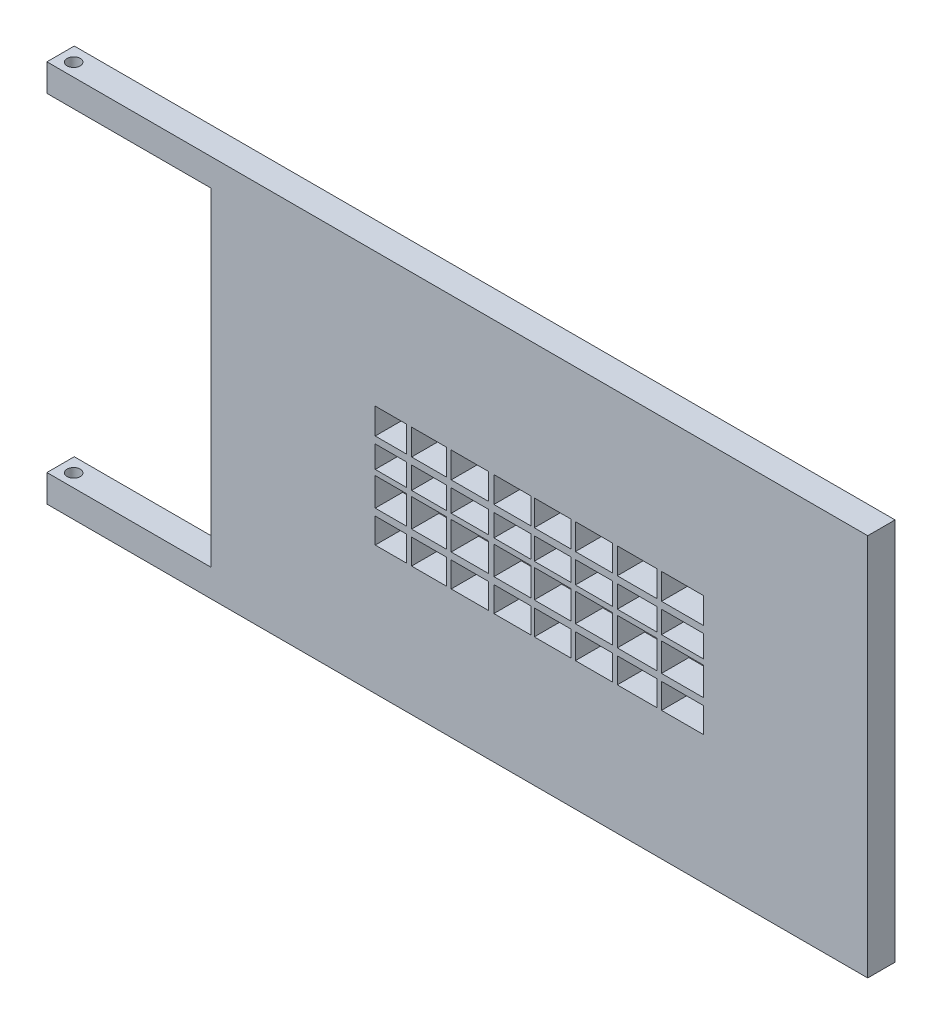
from build123d import *

# Parameters (mm, degrees)
SKETCH1_W               = 600
SKETCH1_H               = 350
BOSS_EXTRUDE1_DEPTH     = 25
SKETCH3_W               = 25
SKETCH3_H               = 25
BOSS_EXTRUDE2_DEPTH     = 150
SKETCH4_R               = 6
CUT_EXTRUDE1_DEPTH      = 370
SKETCH5_W               = 28.359872958
SKETCH5_H               = 23.680958907
SKETCH5_W_2             = 32.02157976
SKETCH5_W_3             = 34.109943658
SKETCH5_W_4             = 34.109943657
SKETCH5_W_5             = 33.413822358
SKETCH5_W_6             = 36.198307555
SKETCH5_W_7             = 38.439491831
SKETCH5_H_2             = 20.187517675
SKETCH5_H_3             = 25.762905436
SKETCH5_H_4             = 22.972002872
CUT_EXTRUDE3_DEPTH      = 30
SKETCH7_W               = 11
SKETCH7_H               = 213.013117536
BOSS_EXTRUDE4_DEPTH     = 30
SKETCH8_W               = 41.071156649
SKETCH8_H               = 6.265091692
BOSS_EXTRUDE5_DEPTH     = 30
SKETCH11_R              = 8
CUT_EXTRUDE6_DEPTH      = 217
CUT_EXTRUDE6_DEPTH_BACK = 4


with BuildPart() as part:
    # Sketch1 → Boss-Extrude1 (new body)
    with BuildSketch(Plane.XY):
        with Locations((300, 175)):
            Rectangle(SKETCH1_W, SKETCH1_H)
    extrude(amount=BOSS_EXTRUDE1_DEPTH)

    # Sketch3 → Boss-Extrude2 (add)
    with BuildSketch(Plane.ZY):
        with Locations((12.5, 12.5)):
            Rectangle(SKETCH3_W, SKETCH3_H)
        with Locations((12.5, 337.5)):
            Rectangle(SKETCH3_W, SKETCH3_H)
    extrude(amount=BOSS_EXTRUDE2_DEPTH)

    # Sketch4 → Cut-Extrude1 (cut)
    with BuildSketch(Plane.XZ):
        with Locations((-137.5, 13.055008402)):
            Circle(SKETCH4_R)
    extrude(amount=-CUT_EXTRUDE1_DEPTH, mode=Mode.SUBTRACT)

    # Sketch5 → Cut-Extrude3 (cut)
    with BuildSketch(Plane.XY.offset(25)):
        with Locations((164.179936479, 215.729513368)):
            Rectangle(SKETCH5_W, SKETCH5_H)
        with Locations((199.243511932, 215.729513368)):
            Rectangle(SKETCH5_W_2, SKETCH5_H)
        with Locations((236.486001436, 215.729513368)):
            Rectangle(SKETCH5_W_3, SKETCH5_H)
        with Locations((275.468794188, 215.729513368)):
            Rectangle(SKETCH5_W_4, SKETCH5_H)
        with Locations((312.015162392, 215.729513368)):
            Rectangle(SKETCH5_W_5, SKETCH5_H)
        with Locations((349.953773195, 215.729513368)):
            Rectangle(SKETCH5_W_3, SKETCH5_H)
        with Locations((389.284626597, 215.729513368)):
            Rectangle(SKETCH5_W_6, SKETCH5_H)
        with Locations((430.780254085, 215.729513368)):
            Rectangle(SKETCH5_W_7, SKETCH5_H)
        with Locations((164.179936479, 187.530183384)):
            Rectangle(SKETCH5_W, SKETCH5_H_2)
        with Locations((199.243511932, 187.530183384)):
            Rectangle(SKETCH5_W_2, SKETCH5_H_2)
        with Locations((236.486001436, 187.530183384)):
            Rectangle(SKETCH5_W_3, SKETCH5_H_2)
        with Locations((275.468794188, 187.530183384)):
            Rectangle(SKETCH5_W_4, SKETCH5_H_2)
        with Locations((312.015162392, 187.530183384)):
            Rectangle(SKETCH5_W_5, SKETCH5_H_2)
        with Locations((349.953773195, 187.530183384)):
            Rectangle(SKETCH5_W_3, SKETCH5_H_2)
        with Locations((389.284626597, 187.530183384)):
            Rectangle(SKETCH5_W_6, SKETCH5_H_2)
        with Locations((430.780254085, 187.530183384)):
            Rectangle(SKETCH5_W_7, SKETCH5_H_2)
        with Locations((430.780254085, 159.688540103)):
            Rectangle(SKETCH5_W_7, SKETCH5_H_3)
        with Locations((389.284626597, 159.688540103)):
            Rectangle(SKETCH5_W_6, SKETCH5_H_3)
        with Locations((349.953773195, 159.688540103)):
            Rectangle(SKETCH5_W_3, SKETCH5_H_3)
        with Locations((312.015162392, 159.688540103)):
            Rectangle(SKETCH5_W_5, SKETCH5_H_3)
        with Locations((275.468794188, 159.688540103)):
            Rectangle(SKETCH5_W_4, SKETCH5_H_3)
        with Locations((236.486001436, 159.688540103)):
            Rectangle(SKETCH5_W_3, SKETCH5_H_3)
        with Locations((199.243511932, 159.688540103)):
            Rectangle(SKETCH5_W_2, SKETCH5_H_3)
        with Locations((164.179936479, 159.688540103)):
            Rectangle(SKETCH5_W, SKETCH5_H_3)
        with Locations((164.179936479, 129.055994257)):
            Rectangle(SKETCH5_W, SKETCH5_H_4)
        with Locations((199.243511932, 129.055994257)):
            Rectangle(SKETCH5_W_2, SKETCH5_H_4)
        with Locations((236.486001436, 129.055994257)):
            Rectangle(SKETCH5_W_3, SKETCH5_H_4)
        with Locations((275.468794188, 129.055994257)):
            Rectangle(SKETCH5_W_4, SKETCH5_H_4)
        with Locations((312.015162392, 129.055994257)):
            Rectangle(SKETCH5_W_5, SKETCH5_H_4)
        with Locations((349.953773195, 129.055994257)):
            Rectangle(SKETCH5_W_3, SKETCH5_H_4)
        with Locations((389.284626597, 129.055994257)):
            Rectangle(SKETCH5_W_6, SKETCH5_H_4)
        with Locations((430.780254085, 129.055994257)):
            Rectangle(SKETCH5_W_7, SKETCH5_H_4)
    extrude(amount=-CUT_EXTRUDE3_DEPTH, mode=Mode.SUBTRACT)

    # Sketch7 → Boss-Extrude4 (add)
    with BuildSketch(Plane(origin=(0, 0, 0), x_dir=(-1, 0, 0), z_dir=(0, 0, -1))):
        with Locations((-545.980889295, 178.828667145)):
            Rectangle(SKETCH7_W, SKETCH7_H)
    extrude(amount=BOSS_EXTRUDE4_DEPTH)

    # Sketch8 → Boss-Extrude5 (add)
    with BuildSketch(Plane(origin=(0, 0, 0), x_dir=(-1, 0, 0), z_dir=(0, 0, -1))):
        with Locations((-530.945310971, 288.467771759)):
            Rectangle(SKETCH8_W, SKETCH8_H)
        with Locations((-530.945310971, 69.189562531)):
            Rectangle(SKETCH8_W, SKETCH8_H)
    extrude(amount=BOSS_EXTRUDE5_DEPTH)

    # Sketch11 → Cut-Extrude6 (cut, two sides)
    with BuildSketch(Plane.XZ.offset(-285.335225913)) as cut_extrude6_sk:
        with Locations((528.139054201, -14.194336347)):
            Circle(SKETCH11_R)
    extrude(amount=CUT_EXTRUDE6_DEPTH, mode=Mode.SUBTRACT)
    extrude(cut_extrude6_sk.sketch, amount=-CUT_EXTRUDE6_DEPTH_BACK, mode=Mode.SUBTRACT)


solid = part.part
